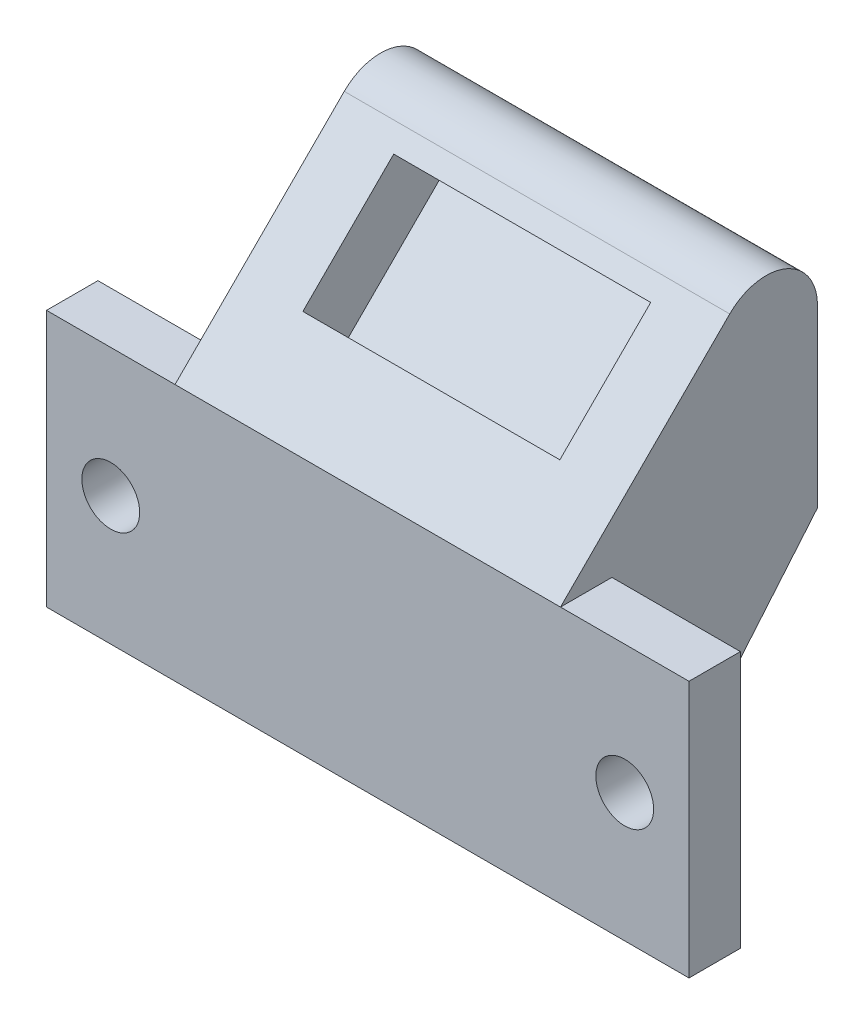
from build123d import *

# Parameters (mm, degrees)
BOSS_EXTRUDE1_DEPTH = 30
SKETCH2_W           = 10
SKETCH2_H           = 20
SKETCH2_R           = 2.25
BOSS_EXTRUDE2_DEPTH = 4
SKETCH3_W           = 20
SKETCH3_H           = 10
CUT_EXTRUDE1_DEPTH  = 5
FILLET1_R           = 4
CHAMFER1_SIZE       = 14
CHAMFER1_SIZE2      = 16.684550296


with BuildPart() as part:
    # Sketch1 → Boss-Extrude1 (new body)
    with BuildSketch(Plane(origin=(0, 0, 0), x_dir=(0, 0, -1), z_dir=(1, 0, 0))):
        Polygon((0, 20), (20, 40), (20, 20), (20, 0), (0, 0), align=None)
    extrude(amount=BOSS_EXTRUDE1_DEPTH)

    # Sketch2 → Boss-Extrude2 (add)
    with BuildSketch(Plane.XY):
        with Locations((-5, 10)):
            Rectangle(SKETCH2_W, SKETCH2_H)
        with Locations((-5, 10)):
            Circle(SKETCH2_R, mode=Mode.SUBTRACT)
        with Locations((35, 10)):
            Rectangle(SKETCH2_W, SKETCH2_H)
        with Locations((35, 10)):
            Circle(SKETCH2_R, mode=Mode.SUBTRACT)
    extrude(amount=-BOSS_EXTRUDE2_DEPTH)

    # Sketch3 → Cut-Extrude1 (cut)
    with BuildSketch(Plane(origin=(0, 10, 10), x_dir=(1, 0, 0), z_dir=(0, 0.707106781, 0.707106781))):
        with Locations((15, 26.142135624)):
            Rectangle(SKETCH3_W, SKETCH3_H)
    extrude(amount=-CUT_EXTRUDE1_DEPTH, mode=Mode.SUBTRACT)

    # Fillet1
    fillet1_edges = [part.edges().sort_by_distance(p)[0] for p in [
        (15, 40, -20),
    ]]
    fillet(fillet1_edges, radius=FILLET1_R)

    # Chamfer1
    chamfer1_edges = [part.edges().sort_by_distance(p)[0] for p in [
        (15, 0, -20),
    ]]
    chamfer1_side = [part.faces().sort_by_distance(p)[0] for p in [
        (15, 0, -9.058823529),
    ]]
    chamfer(chamfer1_edges, length=CHAMFER1_SIZE, length2=CHAMFER1_SIZE2, reference=chamfer1_side[0])


solid = part.part
